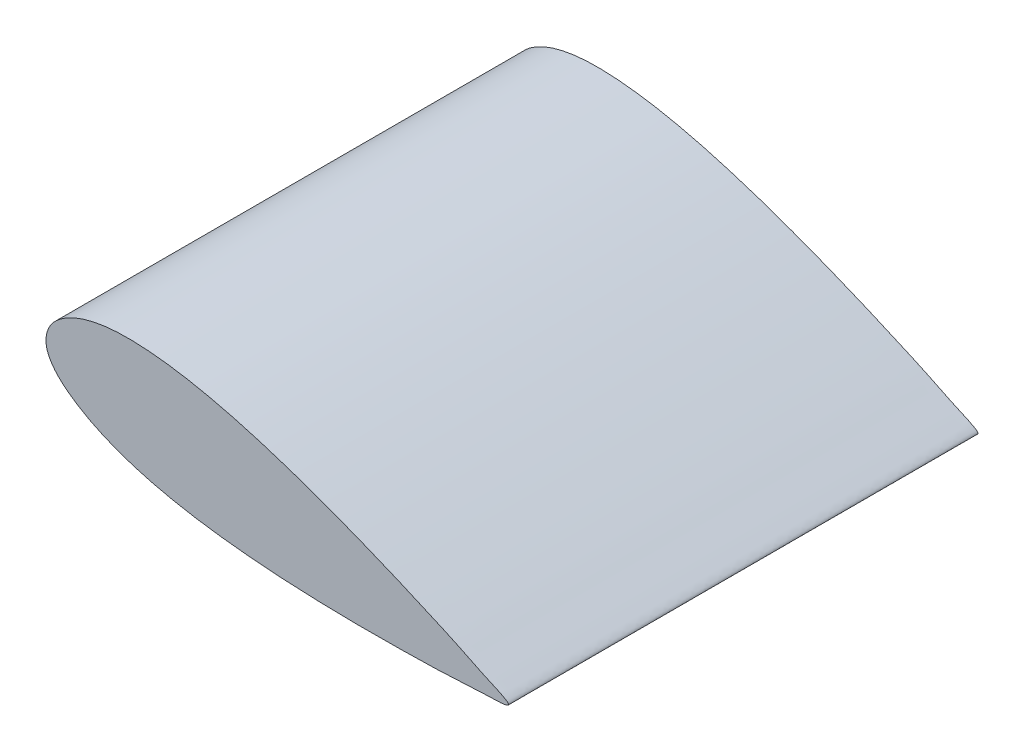
from build123d import *

# Parameters (mm, degrees)
DODANIE_WYCI_GNI_CIE1_DEPTH = 500


with BuildPart() as part:
    # Szkic1 → Dodanie-wyciągnięcie1 (new body)
    with BuildSketch(Plane.XY):
        with BuildLine():
            add(Edge.make_bspline(
                [(492.403876506, -86.824088833), (492.954183925, -84.056739131), (466.167050612, -73.020394711), (440.4954198, -59.702750111), (398.944764946, -41.200533372), (352.759831895, -21.46465106), (305.261359517, -2.754456166), (257.718655375, 14.254293133), (209.655239797, 29.166087807), (169.045923455, 39.154892742), (136.154275259, 44.956657836), (110.776924633, 47.928188315), (83.968221885, 49.212526813), (60.349729442, 47.493234554), (40.712111585, 43.018027414), (25.427584984, 37.224527859), (12.982006711, 29.259893539), (2.143667563, 17.449457735), (-2.596192564, -0.323843799), (5.485665638, -15.770676983), (15.252378702, -26.377426249), (24.521349021, -33.992203672), (35.11942239, -41.05777935), (48.674125762, -48.810247008), (66.411571462, -57.08161328), (89.026969187, -65.311076906), (112.853153061, -72.039844277), (145.455392904, -79.286778013), (186.789762441, -85.621098636), (236.896604511, -90.2638794), (287.326152898, -92.771588287), (338.370833109, -93.69562896), (388.594513344, -93.148882604), (434.062947006, -91.980173696), (462.879035258, -89.52716032), (491.853471045, -89.591931562), (492.403876506, -86.824088833)],
                knots=[0, 0, 0, 0, 0.024751438, 0.049069821, 0.097467709, 0.145589495, 0.193458263, 0.24106869, 0.28843217, 0.335581783, 0.359147002, 0.382782142, 0.40774454, 0.43492595, 0.449379231, 0.464530499, 0.480954839, 0.49056519, 0.50953102, 0.52828423, 0.536925318, 0.55040127, 0.562003597, 0.572911618, 0.594499634, 0.617220072, 0.640855961, 0.664417998, 0.71156974, 0.758924089, 0.806536476, 0.854407487, 0.902531284, 0.950929565, 0.975244152, 1, 1, 1, 1], degree=3))
        make_face()
    extrude(amount=DODANIE_WYCI_GNI_CIE1_DEPTH)


solid = part.part
